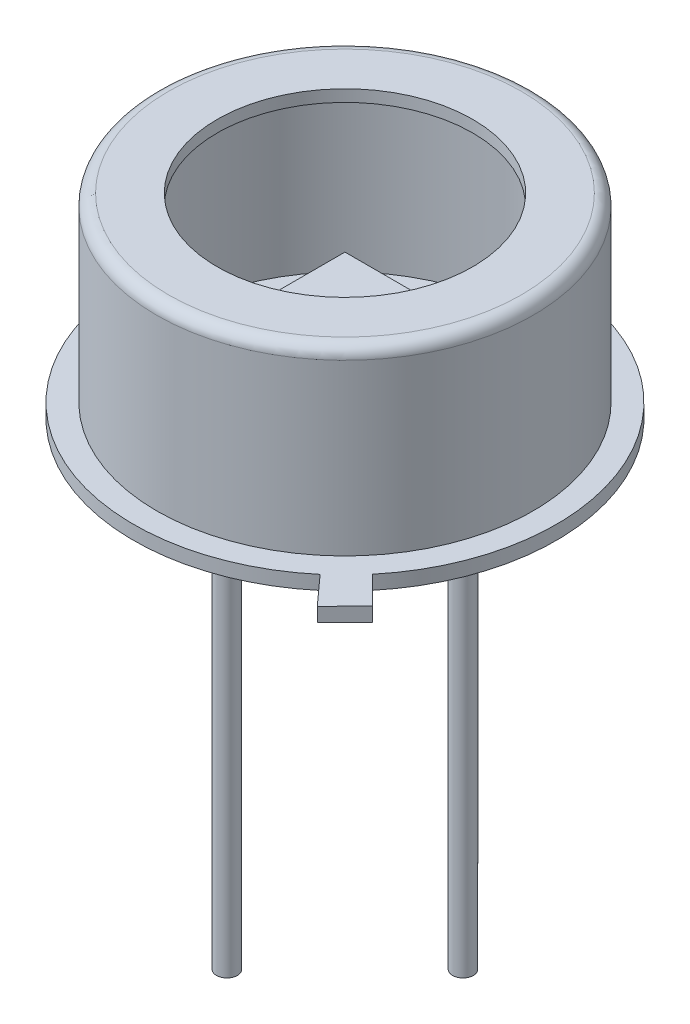
from build123d import *

# Parameters (mm, degrees)
SKETCH2_R           = 4.55
BOSS_EXTRUDE1_DEPTH = 0.046
BOSS_EXTRUDE2_START = -2.1
SKETCH3_W           = 2
SKETCH3_H           = 2
BOSS_EXTRUDE2_DEPTH = 0.508
BOSS_EXTRUDE3_DEPTH = 0.3
SKETCH5_R           = 0.225
BOSS_EXTRUDE4_DEPTH = 9
SKETCH7_R           = 0.75
BOSS_EXTRUDE5_DEPTH = 0.4


with BuildPart() as part:
    # Sketch1 → Revolve-Thin2 (revolve)
    with BuildSketch(Plane.XY, mode=Mode.PRIVATE) as revolve_thin2_sk:
        with BuildLine():
            Line((4.55, 0), (4.55, 0.3))
            Line((4.55, 0.3), (4.05, 0.3))
            Line((4.05, 0.3), (4.05, 3.946))
            ThreePointArc((4.05, 3.946), (3.975605122, 4.125605122), (3.796, 4.2))
            Line((3.796, 4.2), (2.75, 4.2))
            Line((2.75, 4.2), (2.75, 3.946))
            Line((2.75, 3.946), (3.796, 3.946))
            Line((3.796, 3.946), (3.796, 0.046))
            Line((3.796, 0.046), (4.296, 0.046))
            Line((4.296, 0.046), (4.296, 0))
            Line((4.296, 0), (4.55, 0))
        make_face()
    revolve(revolve_thin2_sk.sketch.rotate(Axis((0, 0, 0), (0, 1, 0)), 90), axis=Axis((0, 0, 0), (0, 1, 0)))  # turned: the seam where the file's is

    # Sketch2 → Boss-Extrude1 (add)
    with BuildSketch(Plane.XZ):
        with Locations(Location((0, 0, 0), (0, 0, 270))):  # turned: the seam where the file's is
            Circle(SKETCH2_R)
    extrude(amount=-BOSS_EXTRUDE1_DEPTH)

    # Sketch4 → Boss-Extrude3 (add)
    with BuildSketch(Plane.XZ):
        Polygon((3.499150564, 2.908340649), (2.938865798, 3.473552623), (3.503435617, 4.099455918), (4.096846657, 3.500826355), align=None)
    extrude(amount=-BOSS_EXTRUDE3_DEPTH)

    # Sketch5 → Boss-Extrude4 (add)
    with BuildSketch(Plane.XZ):
        with Locations(Location((-2.54, 0, 0), (0, 0, 90))):  # turned: the seam where the file's is
            Circle(SKETCH5_R)
        with Locations(Location((2.54, 0, 0), (0, 0, 90))):  # turned: the seam where the file's is
            Circle(SKETCH5_R)
        with Locations(Location((0, 2.54, 0), (0, 0, 90))):  # turned: the seam where the file's is
            Circle(SKETCH5_R)
    extrude(amount=BOSS_EXTRUDE4_DEPTH)

    # Sketch7 → Boss-Extrude5 (add)
    with BuildSketch(Plane.XZ):
        with Locations(Location((0, 2.54, 0), (0, 0, 90))):  # turned: the seam where the file's is
            Circle(SKETCH7_R)
    extrude(amount=BOSS_EXTRUDE5_DEPTH)


with BuildPart() as body_2:
    # Sketch3 → Boss-Extrude2 (new body)
    with BuildSketch(Plane.XZ.offset(BOSS_EXTRUDE2_START)):
        Rectangle(SKETCH3_W, SKETCH3_H)
    extrude(amount=BOSS_EXTRUDE2_DEPTH)


solid = Compound([part.part, body_2.part])
